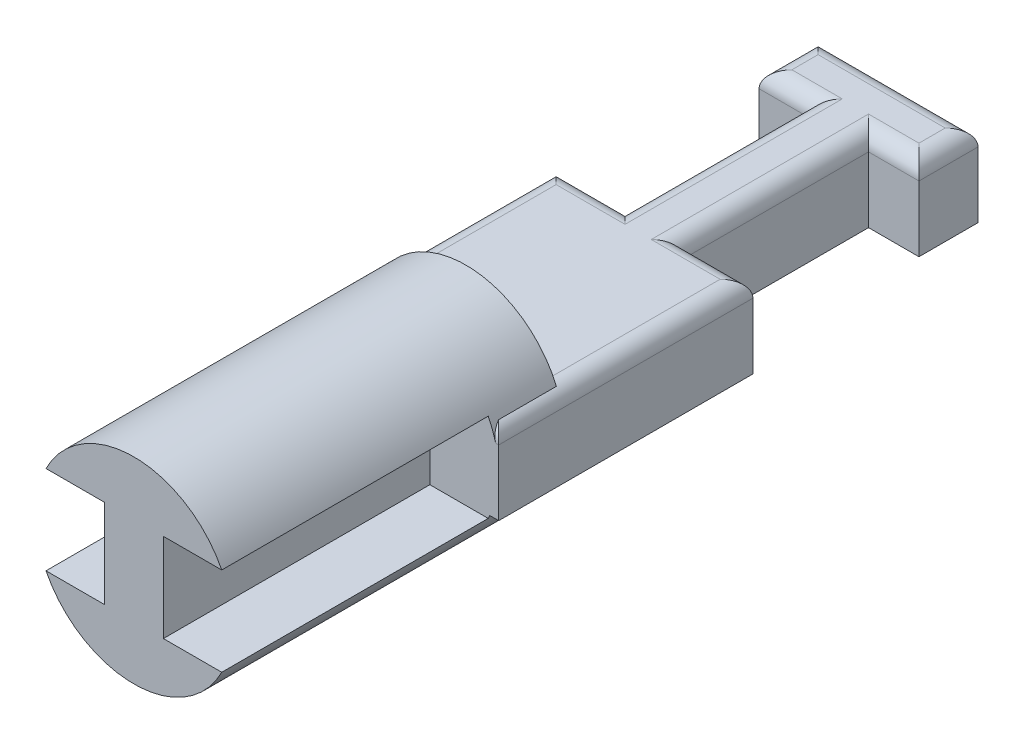
from build123d import *

# Parameters (mm, degrees)
SKETCH1_W           = 1.8
SKETCH1_H           = 21.5
SKETCH1_H_2         = 5.625
SKETCH1_W_2         = 2.1
SKETCH1_H_3         = 7.75
SKETCH1_H_4         = 8.125
BOSS_EXTRUDE1_DEPTH = 1.25
FILLET1_R           = 0.5
BOSS_EXTRUDE2_DEPTH = 2
SKETCH4_W           = 1.8
SKETCH4_H           = 0.1
BOSS_EXTRUDE3_DEPTH = 8.125


with BuildPart() as part:
    # Sketch1 → Boss-Extrude1 (new body, symmetric)
    with BuildSketch(Plane(origin=(0, 0, 0), x_dir=(1, 0, 0), z_dir=(0, 1, 0))):
        Rectangle(SKETCH1_W, SKETCH1_H)
        Polygon((-2.4375, 10.75), (-0.9, 10.75), (0.9, 10.75), (2.4375, 10.75), (2.4375, 12.55), (-2.4375, 12.55), align=None)
        with Locations((0, 7.9375)):
            Rectangle(SKETCH1_W, SKETCH1_H_2)
        with Locations((-1.95, 1.25)):
            Rectangle(SKETCH1_W_2, SKETCH1_H_3)
        with Locations((1.95, 1.25)):
            Rectangle(SKETCH1_W_2, SKETCH1_H_3)
        with Locations((0, -6.6875)):
            Rectangle(SKETCH1_W, SKETCH1_H_4)
    extrude(amount=BOSS_EXTRUDE1_DEPTH, both=True)

    # Fillet1
    fillet1_edges = [part.edges().sort_by_distance(p)[0] for p in [
        (-1.95, 1.25, -5.125),
        (-3, 1.25, -1.25),
        (-1.95, 1.25, 2.625),
        (-0.9, 1.25, 6.6875),
        (0, 1.25, 10.75),
        (0.9, 1.25, 6.6875),
        (1.95, 1.25, 2.625),
        (3, 1.25, -1.25),
        (-0.9, 1.25, -7.9375),
        (1.95, 1.25, -5.125),
        (0.9, 1.25, -7.9375),
        (1.66875, 1.25, -10.75),
        (2.4375, 1.25, -11.65),
        (0, 1.25, -12.55),
        (-2.4375, 1.25, -11.65),
        (-1.66875, 1.25, -10.75),
    ]]
    fillet(fillet1_edges, radius=FILLET1_R)

    # Sketch3 → Boss-Extrude2 (add)
    with BuildSketch(Plane.XY.offset(2.625)):
        with BuildLine():
            ThreePointArc((2.90473751, 0.75), (0, 3), (-2.90473751, 0.75))
            Line((-2.90473751, 0.75), (-0.9, 0.75))
            Line((-0.9, 0.75), (0.9, 0.75))
            Line((0.9, 0.75), (2.90473751, 0.75))
        make_face()
        with BuildLine():
            Line((2.727178029, -1.25), (0.9, -1.25))
            Line((0.9, -1.25), (-0.9, -1.25))
            Line((-0.9, -1.25), (-2.727178029, -1.25))
            ThreePointArc((-2.727178029, -1.25), (0, -3), (2.727178029, -1.25))
        make_face()
    extrude(amount=-BOSS_EXTRUDE2_DEPTH)

    # Sketch4 → Boss-Extrude3 (add)
    with BuildSketch(Plane.XY.offset(2.625)):
        with BuildLine():
            ThreePointArc((2.679085665, 1.35), (0, 3), (-2.679085665, 1.35))
            Line((-2.679085665, 1.35), (-0.9, 1.35))
            Line((-0.9, 1.35), (0.9, 1.35))
            Line((0.9, 1.35), (2.679085665, 1.35))
        make_face()
        with BuildLine():
            Line((0.9, -1.35), (-0.9, -1.35))
            Line((-0.9, -1.35), (-2.679085665, -1.35))
            ThreePointArc((-2.679085665, -1.35), (0, -3), (2.679085665, -1.35))
            Line((2.679085665, -1.35), (0.9, -1.35))
        make_face()
        with BuildLine():
            Line((0.9, -1.25), (-0.9, -1.25))
            Line((-0.9, -1.25), (-0.9, 0.75))
            ThreePointArc((-0.9, 0.75), (-0.753553391, 1.103553391), (-0.4, 1.25))
            Line((-0.4, 1.25), (0.4, 1.25))
            ThreePointArc((0.4, 1.25), (0.753553391, 1.103553391), (0.9, 0.75))
            Line((0.9, 0.75), (0.9, -1.25))
        make_face()
        with BuildLine():
            Line((0.9, 1.35), (-0.9, 1.35))
            Line((-0.9, 1.35), (-0.9, 0.75))
            ThreePointArc((-0.9, 0.75), (-0.753553391, 1.103553391), (-0.4, 1.25))
            Line((-0.4, 1.25), (0.4, 1.25))
            ThreePointArc((0.4, 1.25), (0.753553391, 1.103553391), (0.9, 0.75))
            Line((0.9, 0.75), (0.9, 1.35))
        make_face()
        with Locations((0, -1.3)):
            Rectangle(SKETCH4_W, SKETCH4_H)
    extrude(amount=BOSS_EXTRUDE3_DEPTH)

    # Sketch5 one side → Revolve1 (revolve)
    with BuildSketch(Plane(origin=(0, 0, 0), x_dir=(0, 0, -1), z_dir=(1, 0, 0))):
        with BuildLine():
            Line((12.55, -0.25), (13.2, -0.25))
            ThreePointArc((13.2, -0.25), (13.009619408, 0.209619408), (12.55, 0.4))
            Line((12.55, 0.4), (12.55, -0.25))
        make_face()
    revolve(axis=Axis((0, -0.25, -12.55), (0, 0, -1)))


solid = part.part
